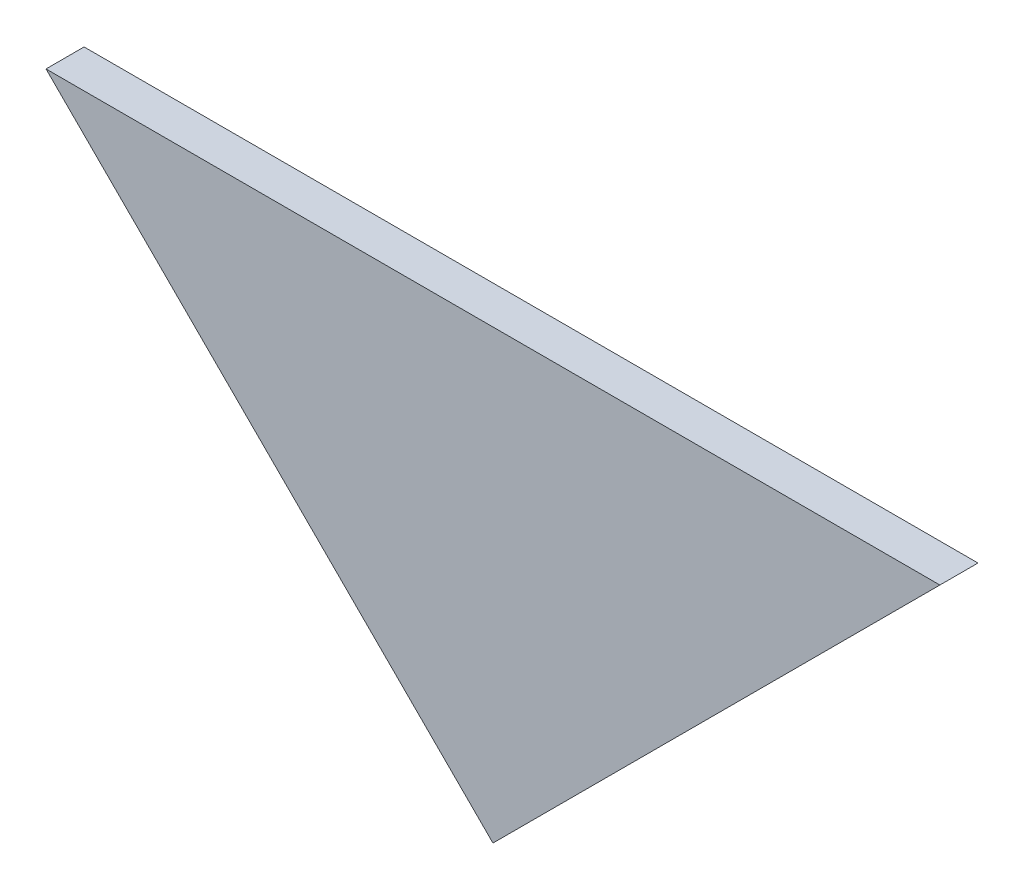
from build123d import *

# Parameters (mm, degrees)
BOSS_EXTRUDE1_DEPTH = 11.90625


with BuildPart() as part:
    # Sketch1 → Boss-Extrude1 (new body)
    with BuildSketch(Plane.XY):
        Polygon((-107.210805256, 37.491131162), (32.489194744, -102.208868838), (172.189194744, 37.491131162), align=None)
    extrude(amount=BOSS_EXTRUDE1_DEPTH)


solid = part.part
